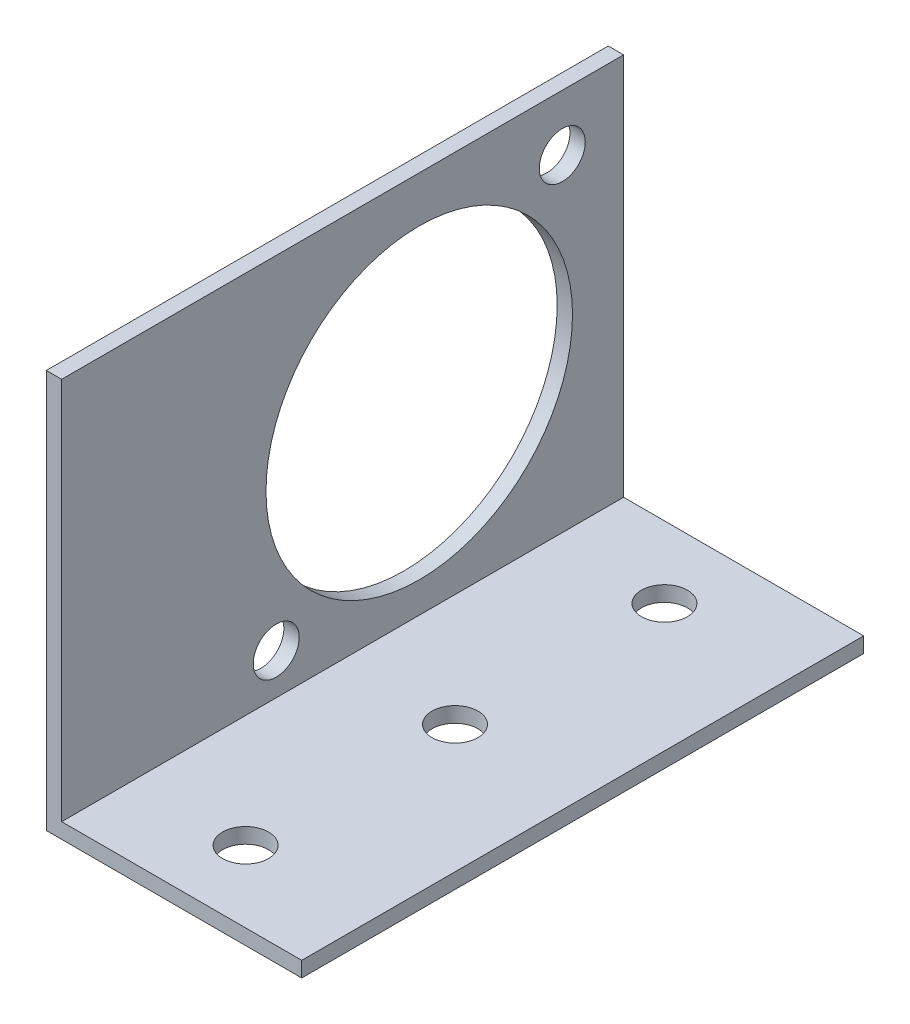
from build123d import *

# Parameters (mm, degrees)
EXTRU_MINCE1_DEPTH    = 55
D_GAGEMENT_M41_D      = 4.5
D_GAGEMENT_M42_D      = 4.5
D_GAGEMENT_M271_D     = 30
D_GAGEMENT_M271_DEPTH = 1.5
D_GAGEMENT_M271_TIP   = 9.012909285


with BuildPart() as part:
    # Esquisse1 → Extru.-Mince1 (new body)
    with BuildSketch(Plane.XY):
        Polygon((0, 39), (0, 0), (25, 0), (25, 1.5), (1.5, 1.5), (1.5, 39), align=None)
    extrude(amount=-EXTRU_MINCE1_DEPTH)

    # Dégagement M41 (through all)
    with Locations(Plane(origin=(0, 1.5, 0), x_dir=(-1, 0, 0), z_dir=(0, 1, 0))):
        with Locations((-12.5, -7), (-12.5, -27.5), (-12.5, -48)):
            Hole(D_GAGEMENT_M41_D / 2)

    # Dégagement M42 (through all)
    with Locations(Plane(origin=(1.5, 0, 0), x_dir=(0, 0, -1), z_dir=(1, 0, 0))):
        with Locations((49, 33.5), (21, 5.5)):
            Hole(D_GAGEMENT_M42_D / 2)

    # Dégagement M271
    with Locations(Plane(origin=(1.5, 0, 0), x_dir=(0, 0, -1), z_dir=(1, 0, 0))):
        with Locations((35, 19.5)):
            Hole(D_GAGEMENT_M271_D / 2, depth=D_GAGEMENT_M271_DEPTH)
            with Locations((0, 0, -(D_GAGEMENT_M271_DEPTH + D_GAGEMENT_M271_TIP / 2))):  # 118° drill point
                Cone(0, D_GAGEMENT_M271_D / 2, D_GAGEMENT_M271_TIP, mode=Mode.SUBTRACT)


solid = part.part
